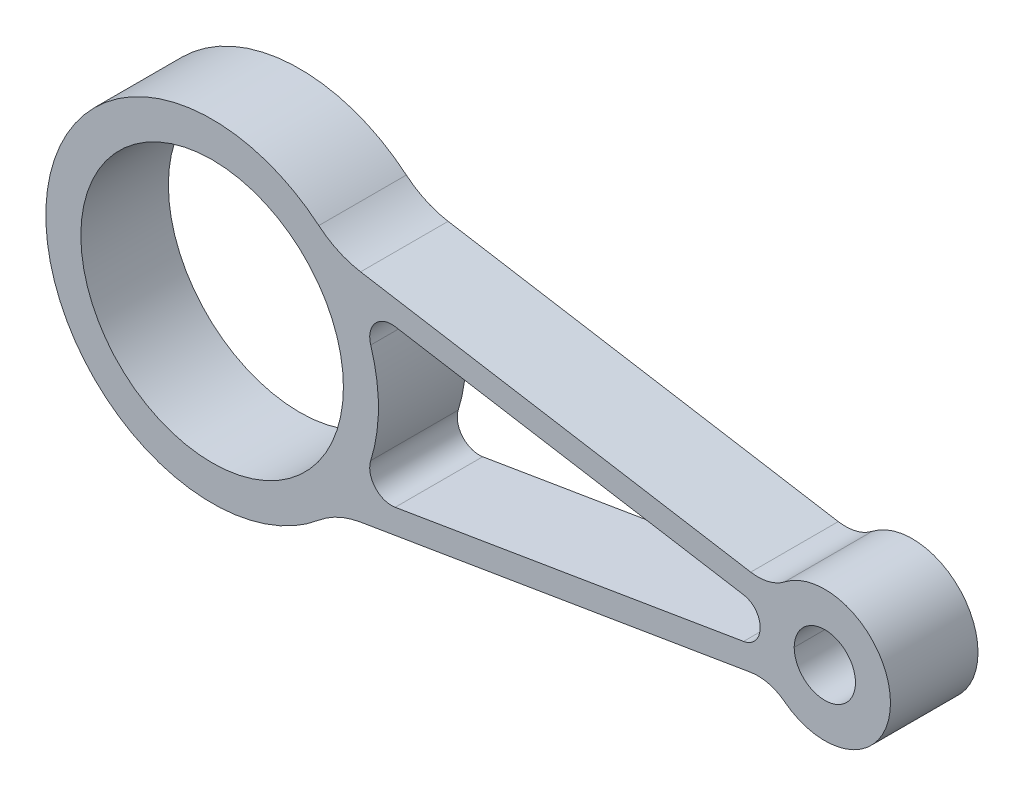
from build123d import *

# Parameters (mm, degrees)
SKETCH1_R          = 30
SKETCH1_R_2        = 7
BASE_EXTRUDE_DEPTH = 20
FILLET1_R          = 10
FILLET2_R          = 20
CUT_EXTRUDE1_DEPTH = 5
CUT_EXTRUDE2_DEPTH = 21


with BuildPart() as part:
    # Sketch1 → Base-Extrude (new body)
    with BuildSketch(Plane.XY):
        with BuildLine():
            Line((27.935473676, 25.760615491), (128.063755469, 9.084385863))
            ThreePointArc((128.063755469, 9.084385863), (155, 0), (128.063755469, -9.084385863))
            Line((128.063755469, -9.084385863), (27.935473676, -25.760615491))
            ThreePointArc((27.935473676, -25.760615491), (-38, 0), (27.935473676, 25.760615491))
        make_face()
        Circle(SKETCH1_R, mode=Mode.SUBTRACT)
        with Locations((140, 0)):
            Circle(SKETCH1_R_2, mode=Mode.SUBTRACT)
    extrude(amount=-BASE_EXTRUDE_DEPTH)

    # Fillet1
    fillet1_edges = [part.edges().sort_by_distance(p)[0] for p in [
        (128.063755469, 9.084385863, -10),
        (128.063755469, -9.084385863, -10),
    ]]
    fillet(fillet1_edges, radius=FILLET1_R)

    # Fillet2
    fillet2_edges = [part.edges().sort_by_distance(p)[0] for p in [
        (27.935473676, 25.760615491, -10),
        (27.935473676, -25.760615491, -10),
    ]]
    fillet(fillet2_edges, radius=FILLET2_R)

    # Sketch2 → Cut-Extrude1 (cut)
    with BuildSketch(Plane.XY):
        with BuildLine():
            Line((41.828554558, 17.870982725), (121.046940728, 4.677267873))
            ThreePointArc((121.046940728, 4.677267873), (123.741079282, 3.147292859), (124.807655013, 0.238406077))
            ThreePointArc((124.807655013, 0.238406077), (123.914202634, -2.958553332), (121.071833732, -4.673121977))
            Line((121.071833732, -4.673121977), (41.828554558, -17.870982725))
            ThreePointArc((41.828554558, -17.870982725), (37.231968897, -16.217361812), (36.238855523, -11.43439331))
            ThreePointArc((36.238855523, -11.43439331), (38, 0), (36.238855523, 11.43439331))
            ThreePointArc((36.238855523, 11.43439331), (37.231968897, 16.217361812), (41.828554558, 17.870982725))
        make_face()
    extrude(amount=-CUT_EXTRUDE1_DEPTH, mode=Mode.SUBTRACT)

    # Sketch3 → Cut-Extrude2 (cut, through all)
    with BuildSketch(Plane(origin=(0, 0, -20), x_dir=(-1, 0, 0), z_dir=(0, 0, -1))):
        with BuildLine():
            Line((-121.445609231, 4.610870174), (-41.828554558, 17.870982725))
            ThreePointArc((-41.828554558, 17.870982725), (-37.231968897, 16.217361812), (-36.238855523, 11.43439331))
            ThreePointArc((-36.238855523, 11.43439331), (-38, 0), (-36.238855523, -11.43439331))
            ThreePointArc((-36.238855523, -11.43439331), (-37.231968897, -16.217361812), (-41.828554558, -17.870982725))
            Line((-41.828554558, -17.870982725), (-121.433526351, -4.612882562))
            ThreePointArc((-121.433526351, -4.612882562), (-124.132861899, -3.076762276), (-125.194211834, -0.157924451))
            ThreePointArc((-125.194211834, -0.157924451), (-124.244145959, 2.952985869), (-121.445609231, 4.610870174))
        make_face()
    extrude(amount=-CUT_EXTRUDE2_DEPTH, mode=Mode.SUBTRACT)


solid = part.part
